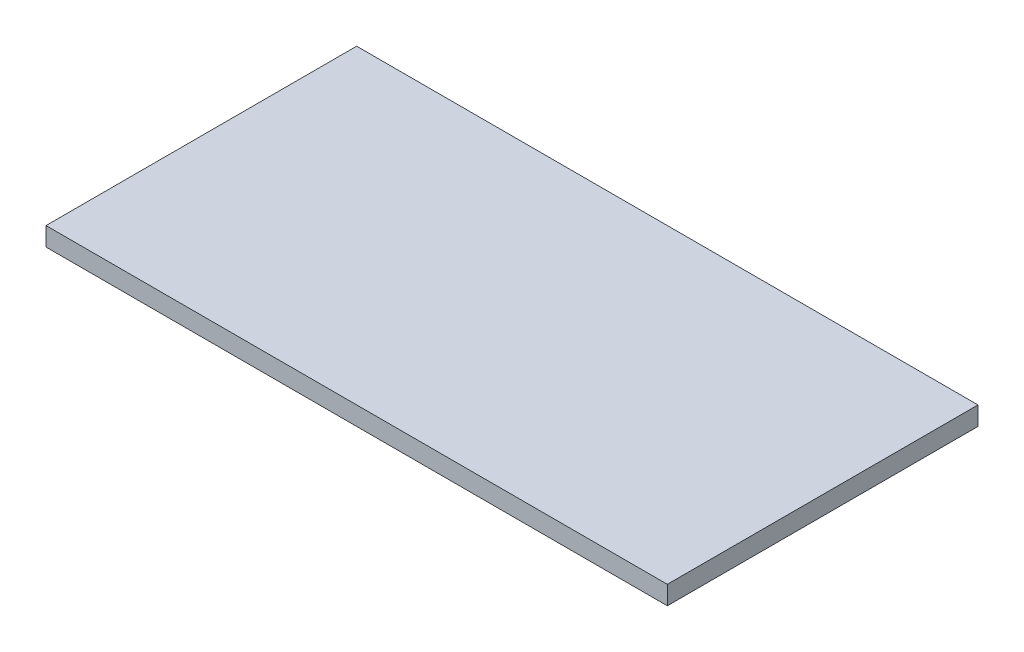
from build123d import *

# Parameters (mm, degrees)
SKETCH1_W           = 1000
SKETCH1_H           = 500
BOSS_EXTRUDE1_DEPTH = 30


with BuildPart() as part:
    # Sketch1 → Boss-Extrude1 (new body)
    with BuildSketch(Plane(origin=(0, 0, 0), x_dir=(1, 0, 0), z_dir=(0, 1, 0))):
        Rectangle(SKETCH1_W, SKETCH1_H)
    extrude(amount=BOSS_EXTRUDE1_DEPTH)


solid = part.part
